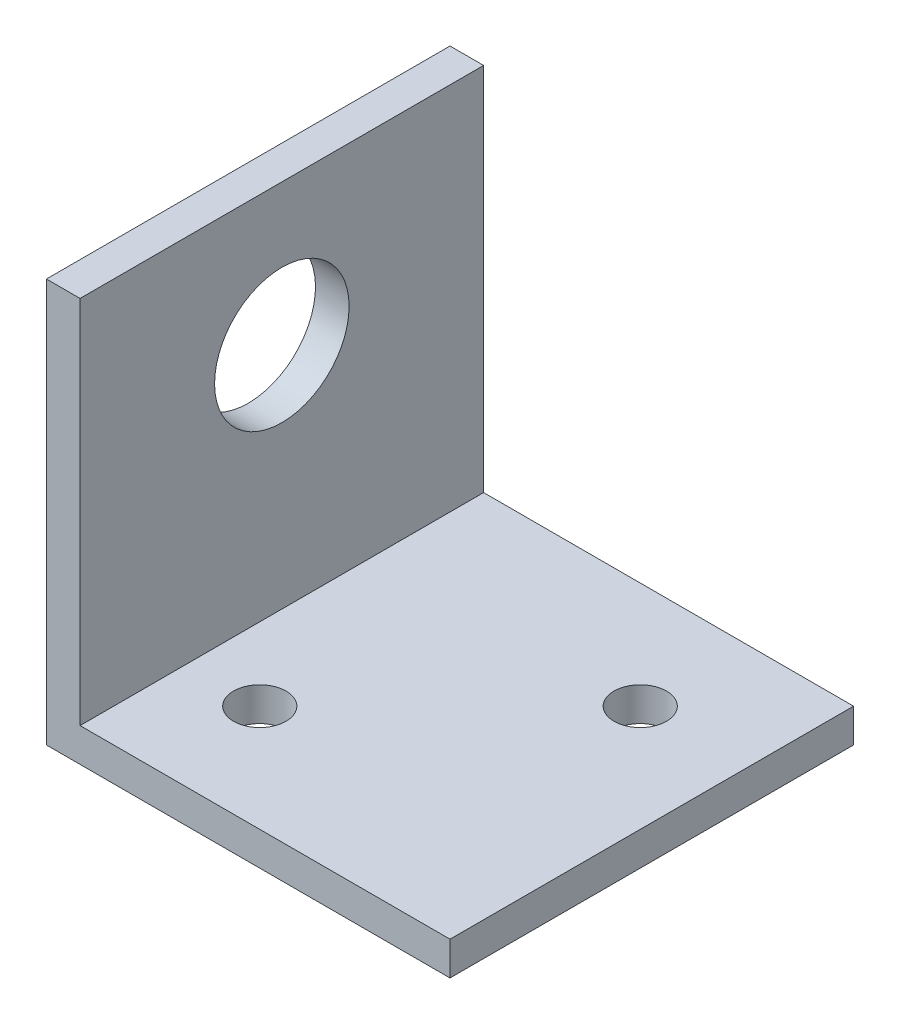
from build123d import *

# Parameters (mm, degrees)
EXTRUDE_THIN1_DEPTH = 38.1
SKETCH2_R           = 6.35
CUT_EXTRUDE1_DEPTH  = 39.1
SKETCH3_R           = 2.4765
CUT_EXTRUDE2_DEPTH  = 39.1


with BuildPart() as part:
    # Sketch1 → Extrude-Thin1 (new body)
    with BuildSketch(Plane.XY):
        Polygon((0, 38.1), (0, 0), (38.1, 0), (38.1, 3.175), (3.175, 3.175), (3.175, 38.1), align=None)
    extrude(amount=EXTRUDE_THIN1_DEPTH)

    # Sketch2 → Cut-Extrude1 (cut, through all)
    with BuildSketch(Plane.ZY):
        with Locations((19.05, 24.765)):
            Circle(SKETCH2_R)
    extrude(amount=-CUT_EXTRUDE1_DEPTH, mode=Mode.SUBTRACT)

    # Sketch3 → Cut-Extrude2 (cut, through all)
    with BuildSketch(Plane.XZ):
        with Locations((28.030256121, 10.069743879)):
            Circle(SKETCH3_R)
        with Locations((10.069743879, 28.030256121)):
            Circle(SKETCH3_R)
    extrude(amount=-CUT_EXTRUDE2_DEPTH, mode=Mode.SUBTRACT)


solid = part.part
